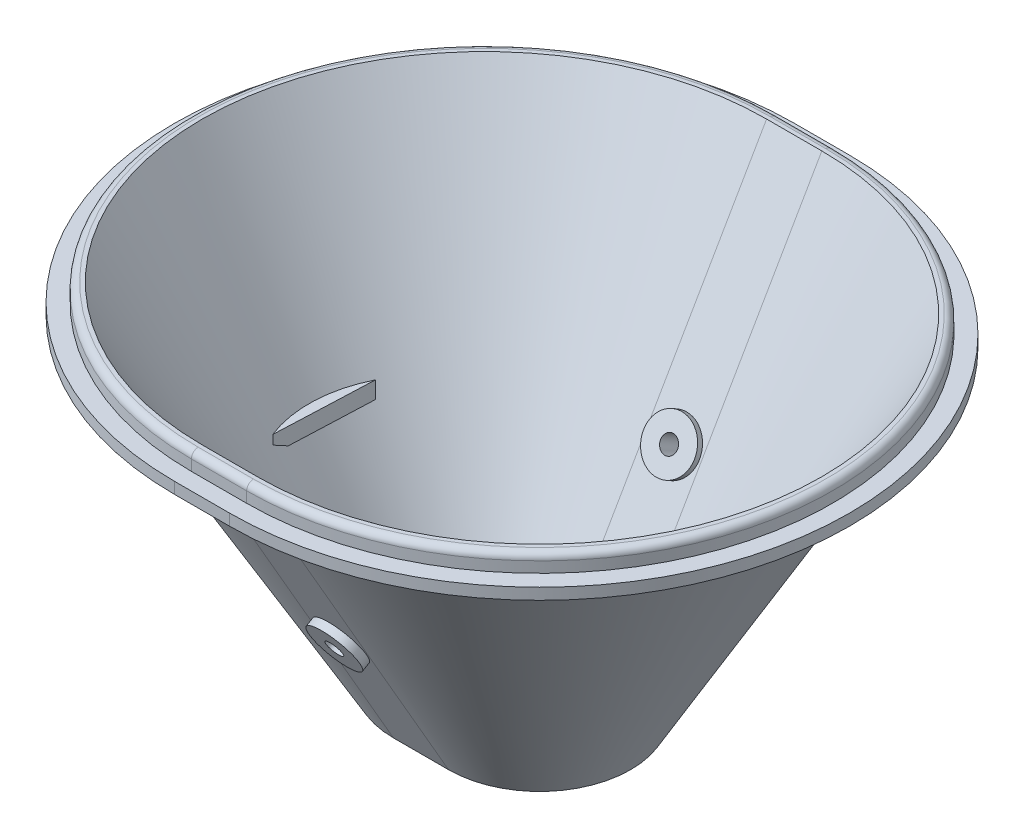
from build123d import *

# Parameters (mm, degrees)
SKETCH7_R                = 2.25
BOSS_EXTRUDE1_DEPTH      = 1.5
BOSS_EXTRUDE1_DEPTH_BACK = 0.5
SKETCH8_R                = 2.25
BOSS_EXTRUDE2_DEPTH      = 1.5
BOSS_EXTRUDE2_DEPTH_BACK = 0.5
SKETCH9_R                = 0.75
CUT_EXTRUDE1_DEPTH       = 2
SKETCH10_R               = 0.75
CUT_EXTRUDE2_DEPTH       = 2
BOSS_EXTRUDE3_DEPTH      = 1.5
CIRPATTERN9_COUNT        = 2
BOSS_EXTRUDE4_DEPTH      = 0.5


with BuildPart() as part:
    # Sweep4: sweep along a path in Sketch4
    with BuildLine(Plane(origin=(0, 16.480353973, 0), x_dir=(1, 0, 0), z_dir=(0, 1, 0))) as sweep4_path:
        Line((5.02848106, -17.422702857), (0.158370698, -17.422702857))
        ThreePointArc((0.158370698, -17.422702857), (-16.341629302, -0.922702857), (0.158370698, 15.577297143))
        Line((0.158370698, 15.577297143), (5.02848106, 15.577297143))
        ThreePointArc((5.02848106, 15.577297143), (21.52848106, -0.922702857), (5.02848106, -17.422702857))
    # Sketch6 → Sweep4 (sweep)
    with BuildSketch(Plane(origin=(0.158370698, 0, 0), x_dir=(0, 0, -1), z_dir=(1, 0, 0))):
        with BuildLine():
            Line((15.577297143, 16.480353973), (6.175266645, 0.195559456))
            Line((6.175266645, 0.195559456), (7.099027076, 0.195559456))
            Line((7.099027076, 0.195559456), (18.633390538, 20.173663005))
            Line((18.633390538, 20.173663005), (23.412127457, 28.450678144))
            Line((23.412127457, 28.450678144), (26.410610213, 28.450678144))
            Line((26.410610213, 28.450678144), (26.410610213, 29.450678144))
            Line((26.410610213, 29.450678144), (24.910610213, 29.450678144))
            Line((24.910610213, 29.450678144), (24.910610213, 30.400678144))
            ThreePointArc((24.910610213, 30.400678144), (24.734874281, 30.824942213), (24.310610213, 31.000678144))
            Line((24.310610213, 31.000678144), (23.960610213, 31.000678144))
            Line((23.960610213, 31.000678144), (15.577297143, 16.480353973))
        make_face()
    sweep(path=sweep4_path.line)

    # Sketch7 → Boss-Extrude1 (add, two sides)
    with BuildSketch(Plane(origin=(0, -2.625079031, -4.546770256), x_dir=(-1, 0, 0), z_dir=(0, -0.5000000000000042, -0.8660254037844363))) as boss_extrude1_sk:
        with Locations(Location((-2.593425879, 17.627679914, 0), (0, 0, 90))):
            Circle(SKETCH7_R)
    extrude(amount=BOSS_EXTRUDE1_DEPTH)
    extrude(boss_extrude1_sk.sketch, amount=-BOSS_EXTRUDE1_DEPTH_BACK)

    # Sketch8 → Boss-Extrude2 (add, two sides)
    with BuildSketch(Plane(origin=(0, -3.424163145, 5.930824541), x_dir=(1, 0, 0), z_dir=(0, -0.5000000000000038, 0.8660254037844365))) as boss_extrude2_sk:
        with Locations(Location((2.593425879, 18.72538277, 0), (0, 0, 270))):
            Circle(SKETCH8_R)
    extrude(amount=BOSS_EXTRUDE2_DEPTH)
    extrude(boss_extrude2_sk.sketch, amount=-BOSS_EXTRUDE2_DEPTH_BACK)

    # Sketch9 → Cut-Extrude1 (cut)
    with BuildSketch(Plane(origin=(0, -4.174163145, 7.229862646), x_dir=(1, 0, 0), z_dir=(0, -0.5000000000000039, 0.8660254037844365))):
        with Locations(Location((2.593425879, 18.72538277, 0), (0, 0, 270))):
            Circle(SKETCH9_R)
    extrude(amount=-CUT_EXTRUDE1_DEPTH, mode=Mode.SUBTRACT)

    # Sketch10 → Cut-Extrude2 (cut)
    with BuildSketch(Plane(origin=(0, -3.375079031, -5.845808362), x_dir=(-1, 0, 0), z_dir=(0, -0.5000000000000041, -0.8660254037844363))):
        with Locations(Location((-2.593425879, 17.627679914, 0), (0, 0, 90))):
            Circle(SKETCH10_R)
    extrude(amount=-CUT_EXTRUDE2_DEPTH, mode=Mode.SUBTRACT)

    # Sketch12 → Boss-Extrude4 (add)
    with BuildSketch(Plane(origin=(0, -3.025079031, -5.239590579), x_dir=(-1, 0, 0), z_dir=(0, -0.5000000000000039, -0.8660254037844365))):
        Polygon((-4.136163067, 12.79891054), (-3.799624606, 12.79891054), (-2.632957939, 10.040697399), (-1.466291272, 12.79891054), (-1.129752811, 12.79891054), (-2.610522042, 9.29891054), (-2.655393837, 9.29891054), align=None)
    extrude(amount=BOSS_EXTRUDE4_DEPTH)


with BuildPart() as body_2:
    # Sketch11 → Boss-Extrude3 (new body)
    with BuildSketch(Plane(origin=(0, 13, 0), x_dir=(1, 0, 0), z_dir=(0, 1, 0))):
        with BuildLine():
            ThreePointArc((19.219175657, 3.540692707), (19.032160287, -0.805032146), (18.855190379, -5.151177668))
            ThreePointArc((18.855190379, -5.151177668), (19.962150039, -0.84397688), (19.219175657, 3.540692707))
        make_face()
    extrude(amount=BOSS_EXTRUDE3_DEPTH)


with BuildPart() as cirpattern9_1:
    # CirPattern9: pattern copy
    add(body_2.part.rotate(Axis((2.593425879, 0, 0.922702857), (0, 1, 0)), 1 * 360 / CIRPATTERN9_COUNT))


solid = Compound([part.part, body_2.part, cirpattern9_1.part])
